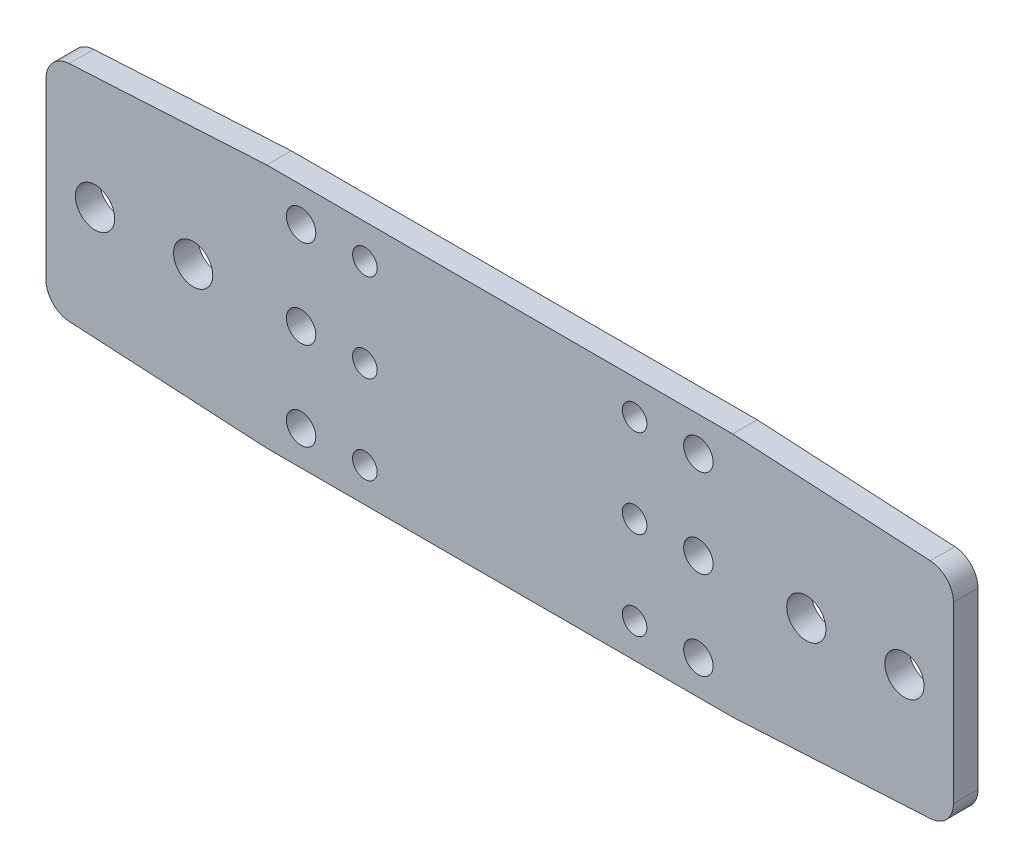
from build123d import *

# Parameters (mm, degrees)
SKETCH1_R           = 4
SKETCH1_R_2         = 2.5
SKETCH1_R_3         = 3
BOSS_EXTRUDE1_DEPTH = 5
FILLET1_R           = 5


with BuildPart() as part:
    # Sketch1 → Boss-Extrude1 (new body)
    with BuildSketch(Plane.XY):
        Polygon((95, 0), (0, 0), (-45, -2.5), (-45, -47.5), (0, -50), (95, -50), (140, -47.5), (140, -2.5), align=None)
        with Locations((-35, -25)):
            Circle(SKETCH1_R, mode=Mode.SUBTRACT)
        with Locations((-15, -25)):
            Circle(SKETCH1_R, mode=Mode.SUBTRACT)
        with Locations((75, -43)):
            Circle(SKETCH1_R_2, mode=Mode.SUBTRACT)
        with Locations((75, -7)):
            Circle(SKETCH1_R_2, mode=Mode.SUBTRACT)
        with Locations((110, -25)):
            Circle(SKETCH1_R, mode=Mode.SUBTRACT)
        with Locations((130, -25)):
            Circle(SKETCH1_R, mode=Mode.SUBTRACT)
        with Locations((20, -25)):
            Circle(SKETCH1_R_2, mode=Mode.SUBTRACT)
        with Locations((75, -25)):
            Circle(SKETCH1_R_2, mode=Mode.SUBTRACT)
        with Locations((7, -25)):
            Circle(SKETCH1_R_3, mode=Mode.SUBTRACT)
        with Locations((88, -25)):
            Circle(SKETCH1_R_3, mode=Mode.SUBTRACT)
        with Locations((20, -7)):
            Circle(SKETCH1_R_2, mode=Mode.SUBTRACT)
        with Locations((20, -43)):
            Circle(SKETCH1_R_2, mode=Mode.SUBTRACT)
        with BuildLine():
            ThreePointArc((7, -40), (4, -43), (7, -46))
            ThreePointArc((7, -46), (10, -43), (7, -40))
        make_face(mode=Mode.SUBTRACT)
        with BuildLine():
            ThreePointArc((88, -46), (91, -43), (88, -40))
            ThreePointArc((88, -40), (85, -43), (88, -46))
        make_face(mode=Mode.SUBTRACT)
        with BuildLine():
            ThreePointArc((88, -10), (91, -7), (88, -4))
            ThreePointArc((88, -4), (85, -7), (88, -10))
        make_face(mode=Mode.SUBTRACT)
        with BuildLine():
            ThreePointArc((7, -10), (10, -7), (7, -4))
            ThreePointArc((7, -4), (4, -7), (7, -10))
        make_face(mode=Mode.SUBTRACT)
    extrude(amount=BOSS_EXTRUDE1_DEPTH)

    # Fillet1
    fillet1_edges = [part.edges().sort_by_distance(p)[0] for p in [
        (140, -2.5, 2.5),
        (140, -47.5, 2.5),
        (-45, -47.5, 2.5),
        (-45, -2.5, 2.5),
    ]]
    fillet(fillet1_edges, radius=FILLET1_R)


solid = part.part
